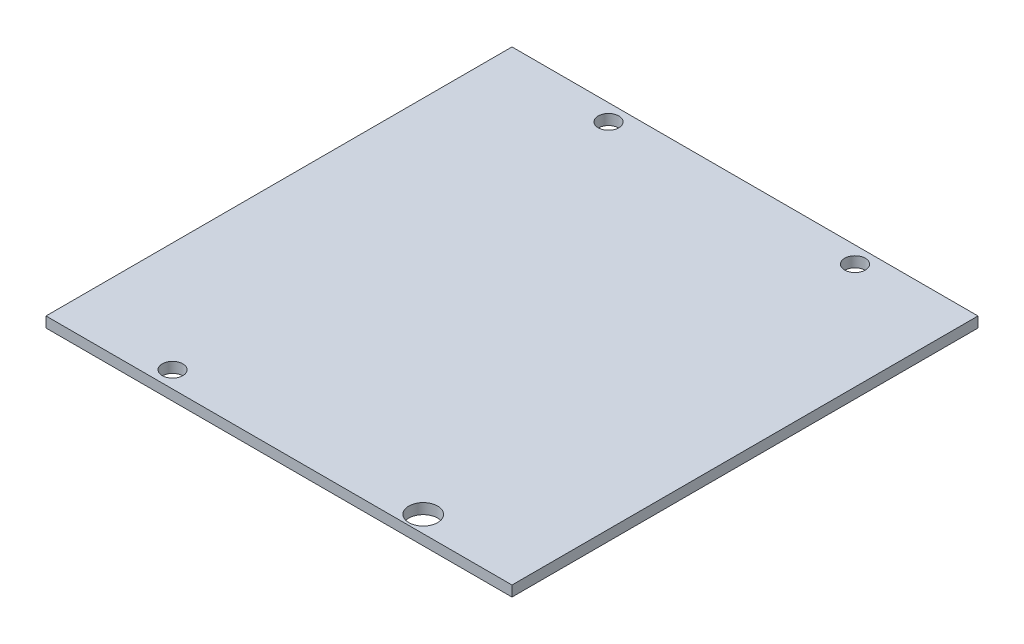
from build123d import *

# Parameters (mm, degrees)
SKETCH1_W           = 88.9
SKETCH1_H           = 88.9
BOSS_EXTRUDE1_DEPTH = 2
SKETCH2_R           = 1.9625
SKETCH2_R_2         = 1.964966766
SKETCH2_R_3         = 2.746799525
SKETCH2_R_4         = 1.962535143
CUT_EXTRUDE1_DEPTH  = 3


with BuildPart() as part:
    # Sketch1 → Boss-Extrude1 (new body)
    with BuildSketch(Plane(origin=(0, 0, 0), x_dir=(1, 0, 0), z_dir=(0, 1, 0))):
        with Locations((44.45, -44.45)):
            Rectangle(SKETCH1_W, SKETCH1_H)
    extrude(amount=BOSS_EXTRUDE1_DEPTH)

    # Sketch2 → Cut-Extrude1 (cut, through all)
    with BuildSketch(Plane(origin=(0, 2, 0), x_dir=(1, 0, 0), z_dir=(0, 1, 0))):
        with Locations((21.592344531, -3.175)):
            Circle(SKETCH2_R)
        with Locations((68.610312584, -3.175)):
            Circle(SKETCH2_R_2)
        with Locations((68.755557213, -85.689765828)):
            Circle(SKETCH2_R_3)
        with Locations((20.95578151, -85.713255276)):
            Circle(SKETCH2_R_4)
    extrude(amount=-CUT_EXTRUDE1_DEPTH, mode=Mode.SUBTRACT)


solid = part.part
